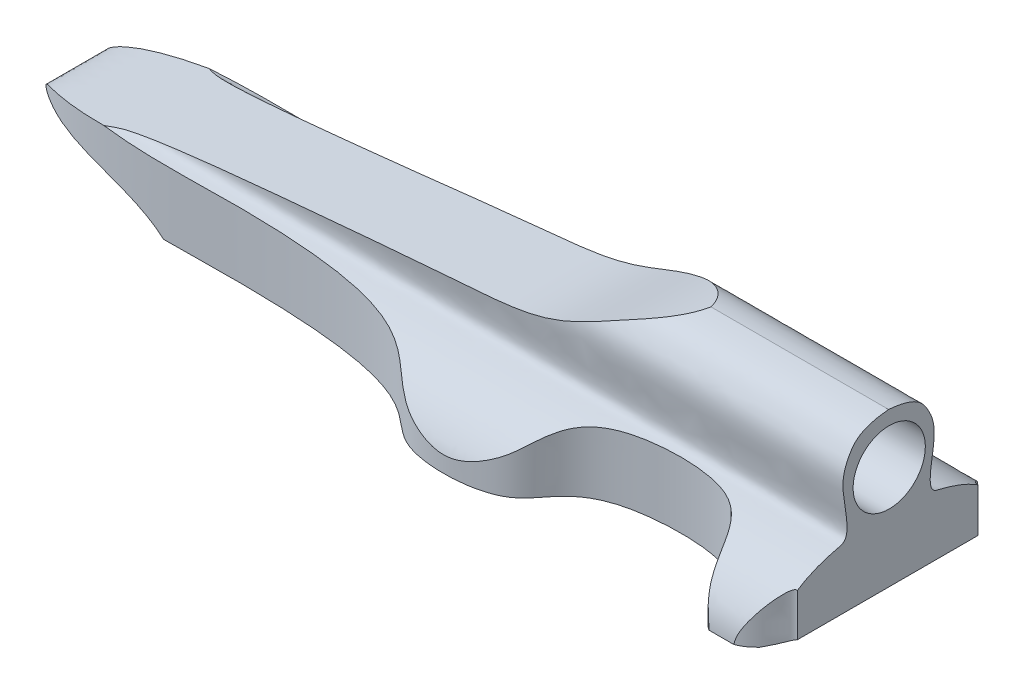
from build123d import *

# Parameters (mm, degrees)
BOSS_EXTRUDE1_DEPTH      = 111
BOSS_EXTRUDE1_DEPTH_BACK = 70
BOSS_EXTRUDE2_DEPTH      = 193
BOSS_EXTRUDE2_DEPTH_BACK = 145
BOSS_EXTRUDE4_DEPTH      = 89
BOSS_EXTRUDE4_DEPTH_BACK = 274
CUT_EXTRUDE2_START       = 22
SKETCH5_R                = 9
CUT_EXTRUDE2_DEPTH       = 52
SKETCH6_W                = 6
SKETCH6_H                = 205.998921158
CUT_EXTRUDE3_DEPTH       = 6


with BuildPart() as part:
    # y face → Boss-Extrude1 (new, two sides: drawn at the far end of the back side and taken through both)
    with BuildSketch(Plane(origin=(0, 0, 0), x_dir=(1, 0, 0), z_dir=(0, 1, 0)).offset(-BOSS_EXTRUDE1_DEPTH_BACK)):
        with BuildLine():
            Line((17.166875903, 8.247019316), (17.166875903, -36.752980684))
            add(Edge.make_bspline(
                [(17.166875903, -36.752980684), (15.76864209, -36.440156775), (12.245553488, -44.449346036), (-2.298526817, -46.050529189), (0.243885166, -25.810106385), (-45.96230052, -26.451299453), (-45.771692603, -43.606011964), (-87.847359856, -44.393470285), (-79.208720813, -26.196573401), (-161.924720279, -28.020233232), (-189.800663406, -25.805789152), (-189.833124097, -14.252980684)],
                knots=[0, 0, 0, 0, 0.08696742, 0.163431131, 0.27771544, 0.359350404, 0.505284938, 0.65013793, 0.910691956, 0.923587394, 1, 1, 1, 1], degree=3))
            add(Edge.make_bspline(
                [(17.166875903, 8.247019316), (15.76864209, 7.934195407), (12.245553488, 15.943384667), (-2.298526817, 17.54456782), (0.243885166, -2.695854983), (-45.96230052, -2.054661915), (-45.771692603, 15.100050596), (-87.847359856, 15.887508917), (-79.208720813, -2.309387967), (-161.924720279, -0.485728136), (-189.800663406, -2.700172217), (-189.833124097, -14.252980684)],
                knots=[0, 0, 0, 0, 0.08696742, 0.163431131, 0.27771544, 0.359350404, 0.505284938, 0.65013793, 0.910691956, 0.923587394, 1, 1, 1, 1], degree=3))
        make_face()
    extrude(amount=BOSS_EXTRUDE1_DEPTH + BOSS_EXTRUDE1_DEPTH_BACK)


with BuildPart() as body_2:
    # z face → Boss-Extrude2 (new, two sides: drawn at the far end of the back side and taken through both)
    with BuildSketch(Plane.XY.offset(-BOSS_EXTRUDE2_DEPTH_BACK)):
        with BuildLine():
            Line((-94.918311964, 119.842134398), (49.686108405, 119.842134398))
            add(Edge.make_bspline(
                [(75.081688036, 129.313820305), (75.046034797, 119.964126883), (49.686108405, 119.842134398)],
                knots=[0, 0, 0, 1, 1, 1], degree=2))
            Line((75.081688036, 129.313820305), (75.081688036, 159.842134398))
            add(Edge.make_bspline(
                [(75.081688036, 159.842134398), (67.899386786, 167.163736369), (18.625212522, 164.140256736), (0.916462476, 147.841168557), (-27.628948172, 146.343414508), (-58.158223276, 143.145922377), (-91.684917802, 139.926455891), (-131.926029784, 135.629696601), (-131.920235461, 133.545683854), (-120.651192429, 128.268612211), (-103.411874774, 129.109554536), (-94.918311964, 119.842134398)],
                knots=[0, 0, 0, 0, 0.194715518, 0.404263689, 0.513481734, 0.564389734, 0.666184176, 0.685801695, 0.704645853, 0.715271131, 1, 1, 1, 1], degree=3))
        make_face()
    extrude(amount=BOSS_EXTRUDE2_DEPTH + BOSS_EXTRUDE2_DEPTH_BACK)


with BuildPart() as body_3:
    # x face → Boss-Extrude4 (new, two sides: drawn at the far end of the back side and taken through both)
    with BuildSketch(Plane(origin=(0, 0, 0), x_dir=(0, 0, -1), z_dir=(1, 0, 0)).offset(-BOSS_EXTRUDE4_DEPTH_BACK)):
        with BuildLine():
            Line((15.981044624, 173.376312682), (-44.018955376, 173.376312682))
            add(Edge.make_bspline(
                [(-14.018955376, 213.376312682), (-20.694319054, 212.813144636), (-25.095778157, 207.481286927), (-25.976229765, 201.042349215), (-23.177836883, 190.421369893), (-28.822952186, 189.428381092), (-43.341162621, 184.996746882), (-44.018955376, 173.376312682)],
                knots=[0, 0, 0, 0, 0.15645542, 0.396872144, 0.6694734, 0.736508246, 1, 1, 1, 1], degree=3))
            add(Edge.make_bspline(
                [(-14.018955376, 213.376312682), (-7.343591697, 212.813144636), (-2.942132594, 207.481286927), (-2.061680986, 201.042349215), (-4.860073869, 190.421369893), (0.785041434, 189.428381092), (15.30325187, 184.996746882), (15.981044624, 173.376312682)],
                knots=[0, 0, 0, 0, 0.15645542, 0.396872144, 0.6694734, 0.736508246, 1, 1, 1, 1], degree=3))
        make_face()
    extrude(amount=BOSS_EXTRUDE4_DEPTH + BOSS_EXTRUDE4_DEPTH_BACK)


with BuildPart() as body_2_1:
    # Body-Move_Copy3: moved
    add(body_2.part.moved(Location((-53.335157743, -73.711702354, 0))))


with BuildPart() as body_2_2:
    # Body-Move_Copy5: moved
    add(body_2_1.part.moved(Location((0, -59.602647039, 0))))

    # Combine3: intersect part
    add(part.part, mode=Mode.INTERSECT)


with BuildPart() as body_3_1:
    # Body-Move_Copy6: moved
    add(body_3.part.moved(Location((-67.272256636, -185.320016644, 0))))


with BuildPart() as body_2_3:
    add(body_2_2.part)

    # Combine3 2: intersect body 3
    add(body_3_1.part, mode=Mode.INTERSECT)

    # Sketch5 → Cut-Extrude2 (cut)
    with BuildSketch(Plane(origin=(0, 0, 0), x_dir=(0, 0, -1), z_dir=(1, 0, 0)).offset(CUT_EXTRUDE2_START)):
        with Locations((-13.871264586, 15.506589636)):
            Circle(SKETCH5_R)
    extrude(amount=-CUT_EXTRUDE2_DEPTH, mode=Mode.SUBTRACT)

    # Sketch6 → Cut-Extrude3 (cut)
    with BuildSketch(Plane(origin=(-10.849787519, -13.493410364, 13.871264586), x_dir=(0, 0, -1), z_dir=(0, 1, 0))):
        with Locations((0.026211337, 75.643850233)):
            Rectangle(SKETCH6_W, SKETCH6_H)
    extrude(amount=CUT_EXTRUDE3_DEPTH, mode=Mode.SUBTRACT)


solid = body_2_3.part
